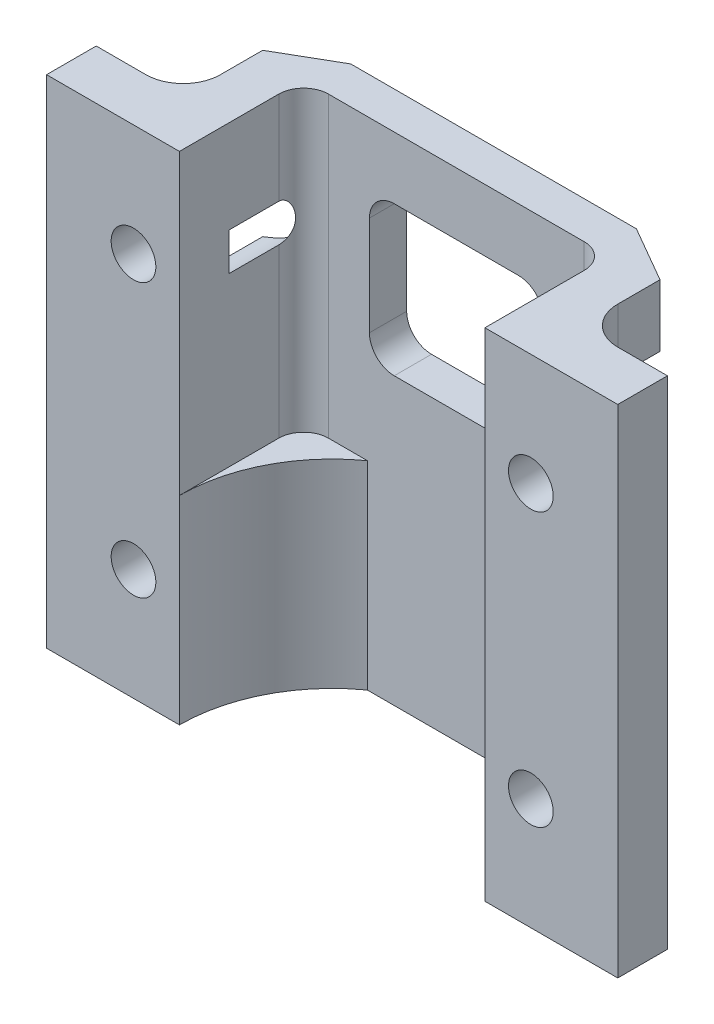
from build123d import *

# Parameters (mm, degrees)
EXTRUDE_1_DEPTH     = 20
SKETCH_2_W          = 12.3
SKETCH_2_H          = 5
CUT_EXTRUDE_1_DEPTH = 12
FILLET_1_R          = 1
FILLET_2_R          = 1.5
CUT_EXTRUDE_5_DEPTH = 21
SKETCH_3_R          = 0.9
CUT_EXTRUDE_2_DEPTH = 8
SKETCH_4_R          = 2
CUT_EXTRUDE_3_DEPTH = 8
CUT_EXTRUDE_4_DEPTH = 8


with BuildPart() as part:
    # 草图1 → 凸台-拉伸1 (new body)
    with BuildSketch(Plane(origin=(0, 0, 0), x_dir=(1, 0, 0), z_dir=(0, 1, 0))):
        with BuildLine():
            Line((-6.15, 0), (-11.5, 0))
            Line((-11.5, 0), (-11.5, 2))
            Line((-11.5, 2), (-8, 2))
            Line((-8, 2), (-8, 6.5))
            Line((-8, 6.5), (8, 6.5))
            Line((8, 6.5), (8, 2))
            Line((8, 2), (11.5, 2))
            Line((11.5, 2), (11.5, 0))
            Line((11.5, 0), (6.15, 0))
            ThreePointArc((6.15, 0), (5.470134317, 2.810717088), (3.580851854, 5))
            Line((3.580851854, 5), (-3.580851854, 5))
            ThreePointArc((-3.580851854, 5), (-5.470134317, 2.810717088), (-6.15, 0))
        make_face()
    extrude(amount=EXTRUDE_1_DEPTH)

    # 草图2 → 切除-拉伸1 (cut)
    with BuildSketch(Plane(origin=(0, 20, 0), x_dir=(1, 0, 0), z_dir=(0, 1, 0))):
        with Locations((0, 2.5)):
            Rectangle(SKETCH_2_W, SKETCH_2_H)
    extrude(amount=-CUT_EXTRUDE_1_DEPTH, mode=Mode.SUBTRACT)

    # 圆角1
    fillet_1_edges = [part.edges().sort_by_distance(p)[0] for p in [
        (-6.15, 14, -5),
        (6.15, 14, -5),
    ]]
    fillet(fillet_1_edges, radius=FILLET_1_R)

    # 圆角2
    fillet_2_edges = [part.edges().sort_by_distance(p)[0] for p in [
        (-8, 10, -2),
        (8, 10, -2),
    ]]
    fillet(fillet_2_edges, radius=FILLET_2_R)

    # 草图6 → 切除-拉伸5 (cut, through all)
    with BuildSketch(Plane(origin=(0, 20, 0), x_dir=(1, 0, 0), z_dir=(0, 1, 0))):
        Polygon((-5.75, 6.5), (-8.528510242, 4.895826364), (-8.528510242, 6.5), align=None)
        Polygon((8.528510242, 6.5), (5.75, 6.5), (8.528510242, 4.895826364), align=None)
    extrude(amount=-CUT_EXTRUDE_5_DEPTH, mode=Mode.SUBTRACT)

    # 草图3 → 切除-拉伸2 (cut)
    with BuildSketch(Plane(origin=(0, 0, -6.5), x_dir=(-1, 0, 0), z_dir=(0, 0, -1))):
        with Locations((-8, 4.5)):
            Circle(SKETCH_3_R)
        with Locations((-8, 15.5)):
            Circle(SKETCH_3_R)
        with Locations((8, 15.5)):
            Circle(SKETCH_3_R)
        with Locations((8, 4.5)):
            Circle(SKETCH_3_R)
    extrude(amount=-CUT_EXTRUDE_2_DEPTH, mode=Mode.SUBTRACT)

    # 草图4 → 切除-拉伸3 (cut)
    with BuildSketch(Plane(origin=(0, 0, -2), x_dir=(-1, 0, 0), z_dir=(0, 0, -1))):
        with Locations((-8, 15.5)):
            Circle(SKETCH_4_R)
        with Locations((-8, 4.5)):
            Circle(SKETCH_4_R)
        with Locations((8, 15.5)):
            Circle(SKETCH_4_R)
        with Locations((8, 4.5)):
            Circle(SKETCH_4_R)
    extrude(amount=CUT_EXTRUDE_3_DEPTH, mode=Mode.SUBTRACT)

    # 草图5 → 切除-拉伸4 (cut)
    with BuildSketch(Plane.XY.offset(-5)):
        with BuildLine():
            Line((-2.5, 17.5), (2.5, 17.5))
            ThreePointArc((2.5, 17.5), (3.207106781, 17.207106781), (3.5, 16.5))
            Line((3.5, 16.5), (3.5, 12.5))
            ThreePointArc((3.5, 12.5), (3.207106781, 11.792893219), (2.5, 11.5))
            Line((2.5, 11.5), (-2.5, 11.5))
            ThreePointArc((-2.5, 11.5), (-3.207106781, 11.792893219), (-3.5, 12.5))
            Line((-3.5, 12.5), (-3.5, 16.5))
            ThreePointArc((-3.5, 16.5), (-3.207106781, 17.207106781), (-2.5, 17.5))
        make_face()
    extrude(amount=-CUT_EXTRUDE_4_DEPTH, mode=Mode.SUBTRACT)


solid = part.part
